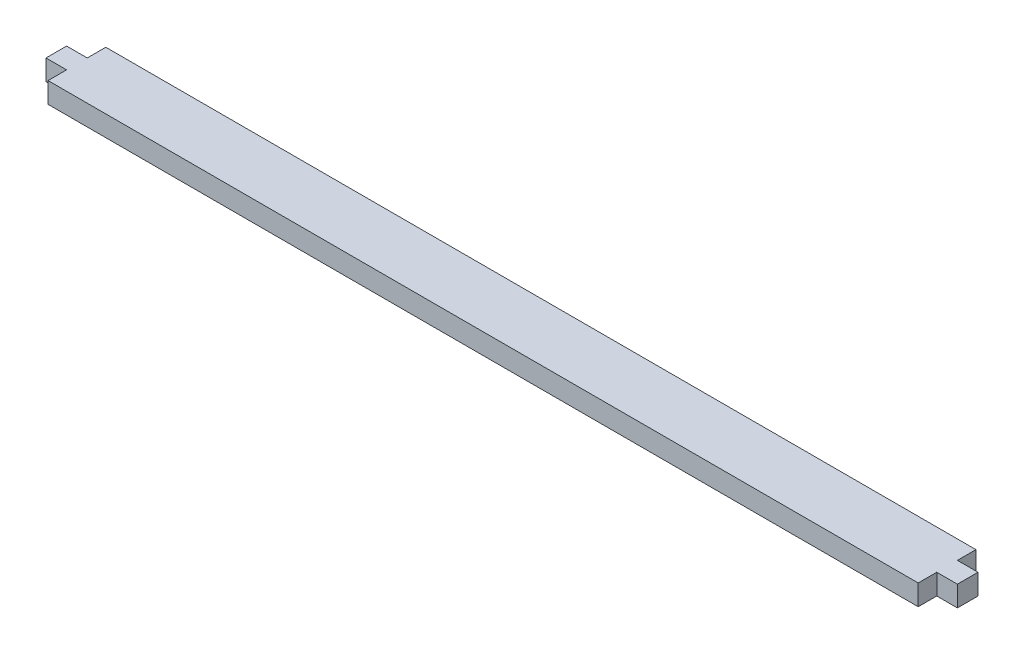
from build123d import *

# Parameters (mm, degrees)
SALIENTE_EXTRUIR1_DEPTH = 10


with BuildPart() as part:
    # Croquis1 → Saliente-Extruir1 (new body)
    with BuildSketch(Plane(origin=(0, 0, 0), x_dir=(1, 0, 0), z_dir=(0, 1, 0))):
        Polygon((-211, 14), (211, 14), (211, 5), (221, 5), (221, -5), (211, -5), (211, -14), (-211, -14), (-211, -5), (-221, -5), (-221, 5), (-211, 5), align=None)
    extrude(amount=SALIENTE_EXTRUIR1_DEPTH)


solid = part.part
